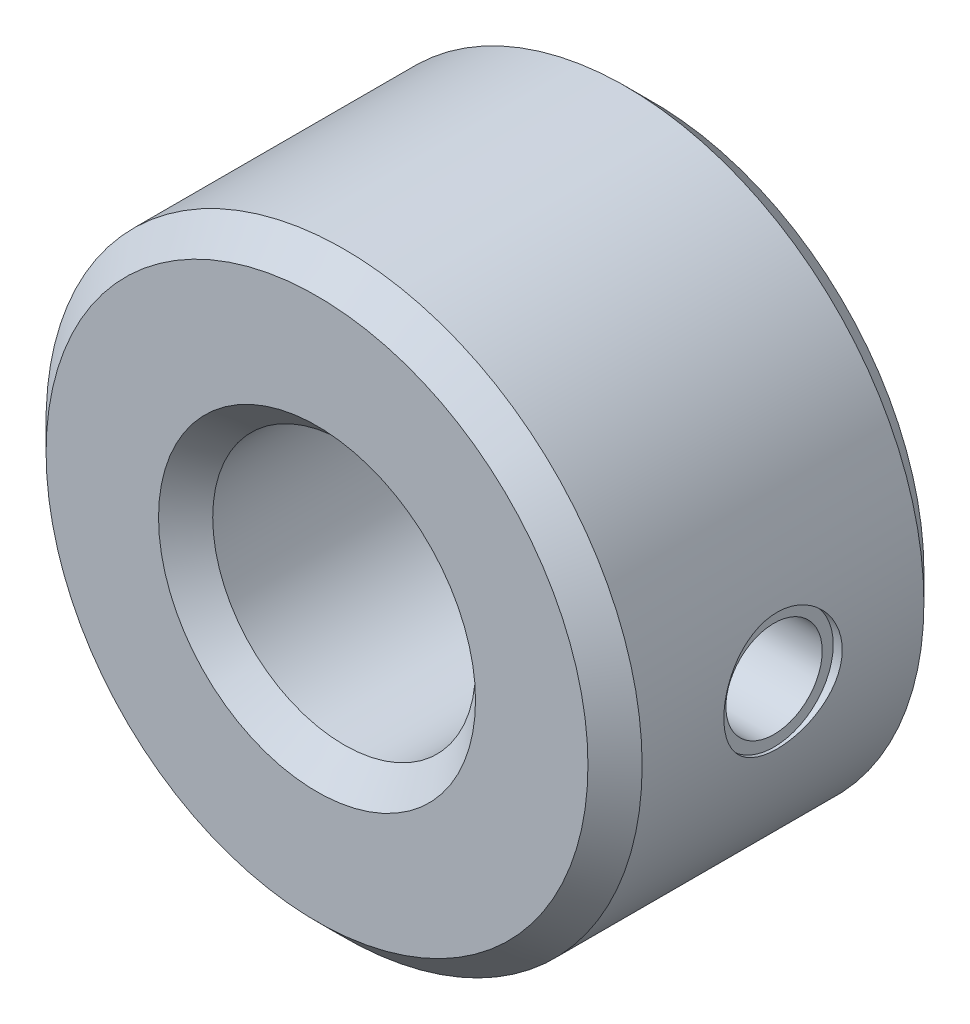
from build123d import *

# Parameters (mm, degrees)
CUT_EXTRUDE1_START         = 5.842
SKETCH4_R                  = 1.0922
CUT_EXTRUDE1_DEPTH         = 0.508
F_2_56_TAPPED_HOLE2_REACH  = 14.539
F_2_56_TAPPED_HOLE2_BORE_R = 0.889


with BuildPart() as part:
    # Sketch1 → Revolve1 (revolve)
    with BuildSketch(Plane(origin=(0, 0, 0), x_dir=(0, 0, -1), z_dir=(1, 0, 0)), mode=Mode.PRIVATE) as revolve1_sk:
        Polygon((-3.1, 5), (-3.1, 2.925), (-2.6, 2.425), (2.6, 2.425), (3.1, 2.925), (3.1, 5), (2.6, 5.5), (-2.6, 5.5), align=None)
    revolve(revolve1_sk.sketch.rotate(Axis((0, 0, 0), (0, 0, -1)), 90), axis=Axis((0, 0, 0), (0, 0, -1)))

    # Sketch4 → Cut-Extrude1 (cut)
    with BuildSketch(Plane(origin=(0, 0, 0), x_dir=(0, 0, -1), z_dir=(1, 0, 0)).offset(CUT_EXTRUDE1_START)):
        Circle(SKETCH4_R)
    extrude(amount=-CUT_EXTRUDE1_DEPTH, mode=Mode.SUBTRACT)

    # 2-56 Tapped Hole2 bore → 2-56 Tapped Hole2 (cut, up to next)
    with BuildSketch(Plane(origin=(5.334, 0, 0), x_dir=(0, 0, -1), z_dir=(1, 0, 0)), mode=Mode.PRIVATE) as f_2_56_tapped_hole2_sk1:
        Circle(F_2_56_TAPPED_HOLE2_BORE_R)
    f_2_56_tapped_hole2_tool1 = extrude(f_2_56_tapped_hole2_sk1.sketch, amount=-F_2_56_TAPPED_HOLE2_REACH, mode=Mode.PRIVATE) & part.part
    add(f_2_56_tapped_hole2_tool1.solids().sort_by_distance((5.334, 0, 0))[0], mode=Mode.SUBTRACT)


solid = part.part
